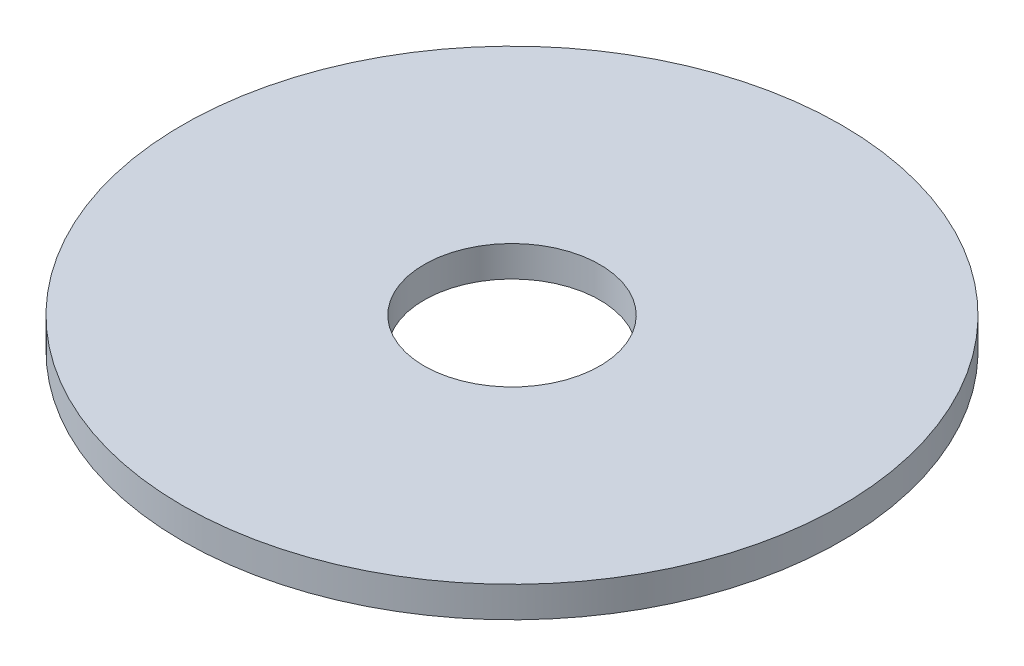
from build123d import *

# Parameters (mm, degrees)
SKETCH1_R           = 15
SKETCH1_R_2         = 4
BOSS_EXTRUDE1_DEPTH = 1.4


with BuildPart() as part:
    # Sketch1 → Boss-Extrude1 (new body)
    with BuildSketch(Plane(origin=(0, 0, 0), x_dir=(1, 0, 0), z_dir=(0, 1, 0))):
        Circle(SKETCH1_R)
        Circle(SKETCH1_R_2, mode=Mode.SUBTRACT)
    extrude(amount=BOSS_EXTRUDE1_DEPTH)


solid = part.part
